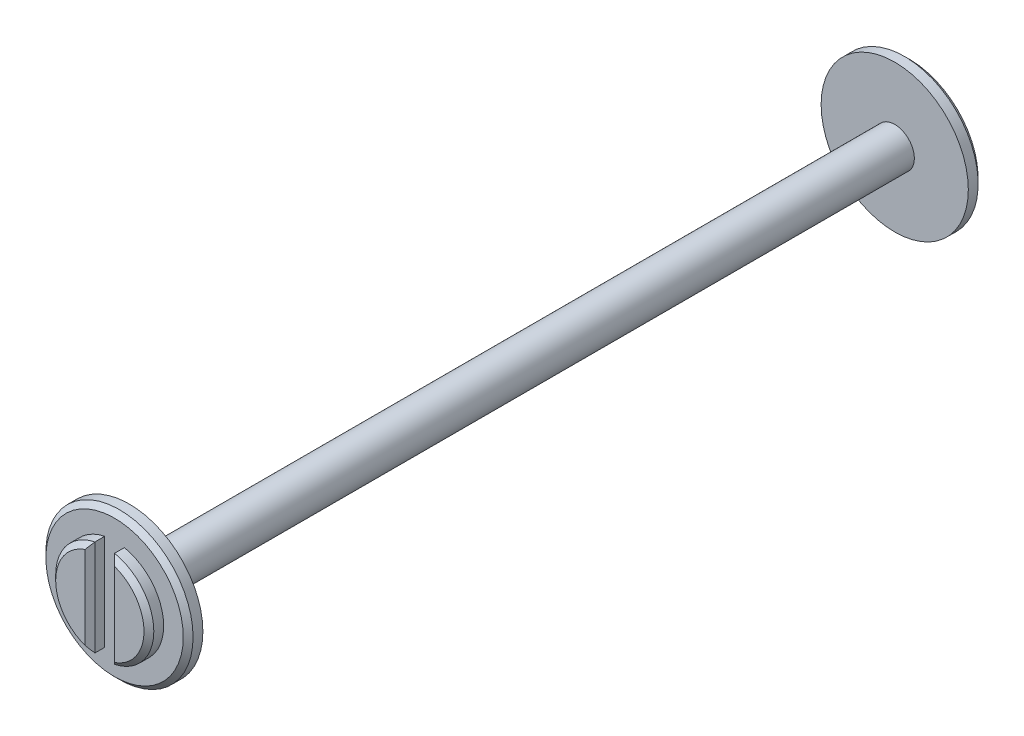
from build123d import *

# Parameters (mm, degrees)
SKETCH1_R           = 7.5
BOSS_EXTRUDE1_DEPTH = 1.5
SKETCH2_R           = 5
BOSS_EXTRUDE2_DEPTH = 1.5
SKETCH3_R           = 2
BOSS_EXTRUDE3_DEPTH = 39
SKETCH4_W           = 2
SKETCH4_H           = 12
CUT_EXTRUDE1_DEPTH  = 1.5
CHAMFER1_SIZE       = 0.5


with BuildPart() as part:
    # Sketch1 → Boss-Extrude1 (new body)
    with BuildSketch(Plane.XY):
        Circle(SKETCH1_R)
    extrude(amount=BOSS_EXTRUDE1_DEPTH)

    # Sketch2 → Boss-Extrude2 (add)
    with BuildSketch(Plane.XY.offset(1.5)):
        Circle(SKETCH2_R)
    extrude(amount=BOSS_EXTRUDE2_DEPTH)

    # Sketch3 → Boss-Extrude3 (add)
    with BuildSketch(Plane(origin=(0, 0, 0), x_dir=(-1, 0, 0), z_dir=(0, 0, -1))):
        Circle(SKETCH3_R)
    extrude(amount=BOSS_EXTRUDE3_DEPTH)

    # Sketch4 → Cut-Extrude1 (cut)
    with BuildSketch(Plane.XY.offset(3)):
        Rectangle(SKETCH4_W, SKETCH4_H)
    extrude(amount=-CUT_EXTRUDE1_DEPTH, mode=Mode.SUBTRACT)

    # Mirror1: part across plane


with BuildPart() as part_1:
    add(part.part)
    add(part.part.mirror(Plane(origin=(0, 0, -39), x_dir=(1, 0, 0), z_dir=(0, 0, -1))))

    # Chamfer1
    chamfer1_edges = [part_1.edges().sort_by_distance(p)[0] for p in [
        (-5, 0, 3),
        (5, 0, 3),
        (-1, 0, 3),
        (1, 0, 3),
        (-7.5, 0, 1.5),
        (5, 0, -81),
        (1, 0, -81),
        (-7.5, 0, -79.5),
        (-5, 0, -81),
        (-1, 0, -81),
    ]]
    chamfer(chamfer1_edges, length=CHAMFER1_SIZE)


solid = part_1.part
